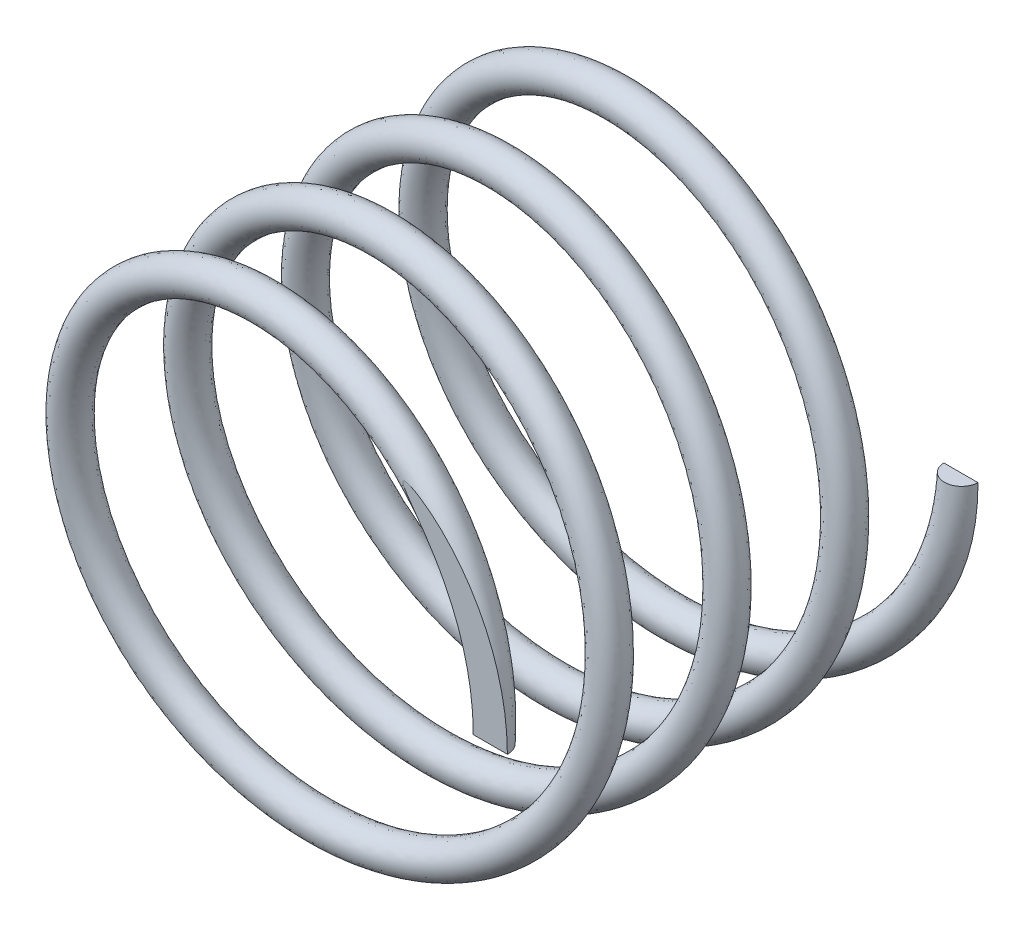
from build123d import *

# Parameters (mm, degrees)
SWEEP1_PITCH       = 13.75
SWEEP1_HEIGHT      = 55
SWEEP1_RADIUS      = 28
SKETCH4_R          = 2
SKETCH7_R          = 41.345540302
CUT_EXTRUDE1_DEPTH = 10
SKETCH9_R          = 42.497076876
CUT_EXTRUDE2_DEPTH = 5


with BuildPart() as part:
    # Sweep1: sweep along a helix
    with BuildLine() as sweep1_path:
        Helix(SWEEP1_PITCH, SWEEP1_HEIGHT, SWEEP1_RADIUS, center=(0, 0, 0), direction=(0, 0, 1), lefthand=True)
    # Sketch4 → Sweep1 (sweep)
    with BuildSketch(Plane(origin=(0, 0, 0), x_dir=(1, 0, 0), z_dir=(0, 1, 0))):
        with Locations((27.984170591, -54.92675962)):
            Circle(SKETCH4_R)
    sweep(path=sweep1_path.line, is_frenet=True)

    # Sketch7 → Cut-Extrude1 (cut)
    with BuildSketch(Plane.XY):
        Circle(SKETCH7_R)
    extrude(amount=-CUT_EXTRUDE1_DEPTH, mode=Mode.SUBTRACT)

    # Sketch9 → Cut-Extrude2 (cut)
    with BuildSketch(Plane.XY.offset(60)):
        Circle(SKETCH9_R)
    extrude(amount=-CUT_EXTRUDE2_DEPTH, mode=Mode.SUBTRACT)


solid = part.part
